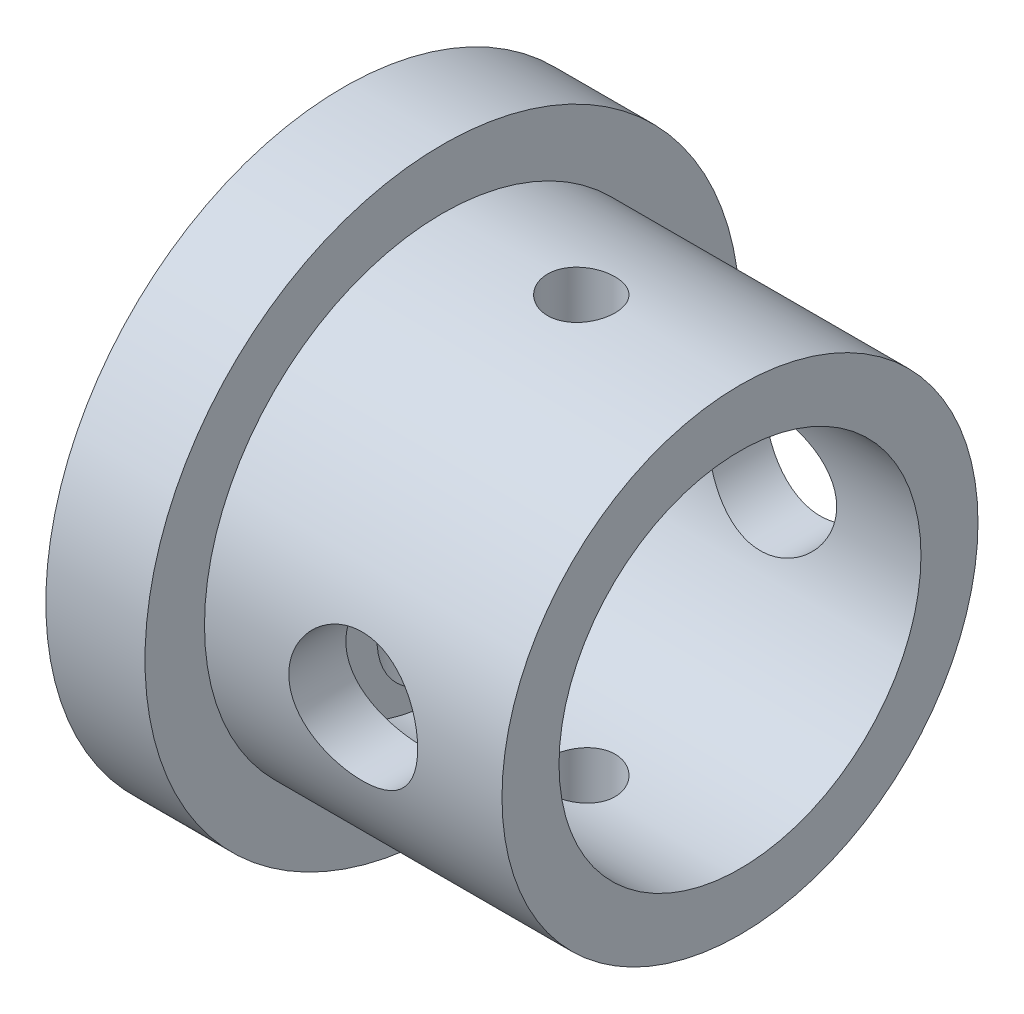
from build123d import *

# Parameters (mm, degrees)
SKETCH_1_R                   = 15
EXTRUDE_1_DEPTH              = 5
SKETCH_1_5_R                 = 12
SKETCH_1_5_R_2               = 9.125
EXTRUDE_2_DEPTH              = 20
HOLE_WIZARD_M3_1_D           = 3.4
HOLE_WIZARD_M3_1_CSINK_D     = 6.6
HOLE_WIZARD_M3_1_CSINK_ANGLE = 90
CUT_EXTRUDE1_DEPTH           = 30.154759474
CUT_EXTRUDE1_DEPTH_BACK      = 30.154759474
SKETCH1_R                    = 3.25
M3_CLEARANCE_HOLE1_D         = 3.4
M3_CLEARANCE_HOLE1_DEPTH     = 35
M3_CLEARANCE_HOLE1_TIP       = 1.021463052


with BuildPart() as part:
    # 草图1 → 凸台-拉伸1 (new body)
    with BuildSketch(Plane(origin=(0, 0, 0), x_dir=(0, 0, -1), z_dir=(1, 0, 0))):
        Circle(SKETCH_1_R)
    extrude(amount=EXTRUDE_1_DEPTH)

    # 草图1<5> → 凸台-拉伸2 (add)
    with BuildSketch(Plane(origin=(0, 0, 0), x_dir=(0, 0, -1), z_dir=(1, 0, 0))):
        Circle(SKETCH_1_5_R)
        Circle(SKETCH_1_5_R_2, mode=Mode.SUBTRACT)
    extrude(amount=EXTRUDE_2_DEPTH)

    # M3 十字槽沉头木螺钉的锥形沉头孔1 (through all)
    with Locations(Plane(origin=(5, 0, 0), x_dir=(0, 0, 1), z_dir=(1, 0, 0))):
        with Locations((0, -5), (-5, 0), (0, 5), (5, 0)):
            CounterSinkHole(HOLE_WIZARD_M3_1_D / 2, HOLE_WIZARD_M3_1_CSINK_D / 2, counter_sink_angle=HOLE_WIZARD_M3_1_CSINK_ANGLE)

    # Sketch1 → Cut-Extrude1 (cut, two sides: drawn at the far end of the back side and taken through both)
    with BuildSketch(Plane.XY.offset(-CUT_EXTRUDE1_DEPTH_BACK)):
        with Locations((12.5, 0)):
            Circle(SKETCH1_R)
    extrude(amount=CUT_EXTRUDE1_DEPTH + CUT_EXTRUDE1_DEPTH_BACK, mode=Mode.SUBTRACT)

    # M3 Clearance Hole1
    with Locations(Plane(origin=(0, -12, 0), x_dir=(-1, 0, 0), z_dir=(0, -1, 0))):
        with Locations((-12, 0)):
            Hole(M3_CLEARANCE_HOLE1_D / 2, depth=M3_CLEARANCE_HOLE1_DEPTH)
            with Locations((0, 0, -(M3_CLEARANCE_HOLE1_DEPTH + M3_CLEARANCE_HOLE1_TIP / 2))):  # 118° drill point
                Cone(0, M3_CLEARANCE_HOLE1_D / 2, M3_CLEARANCE_HOLE1_TIP, mode=Mode.SUBTRACT)


solid = part.part
